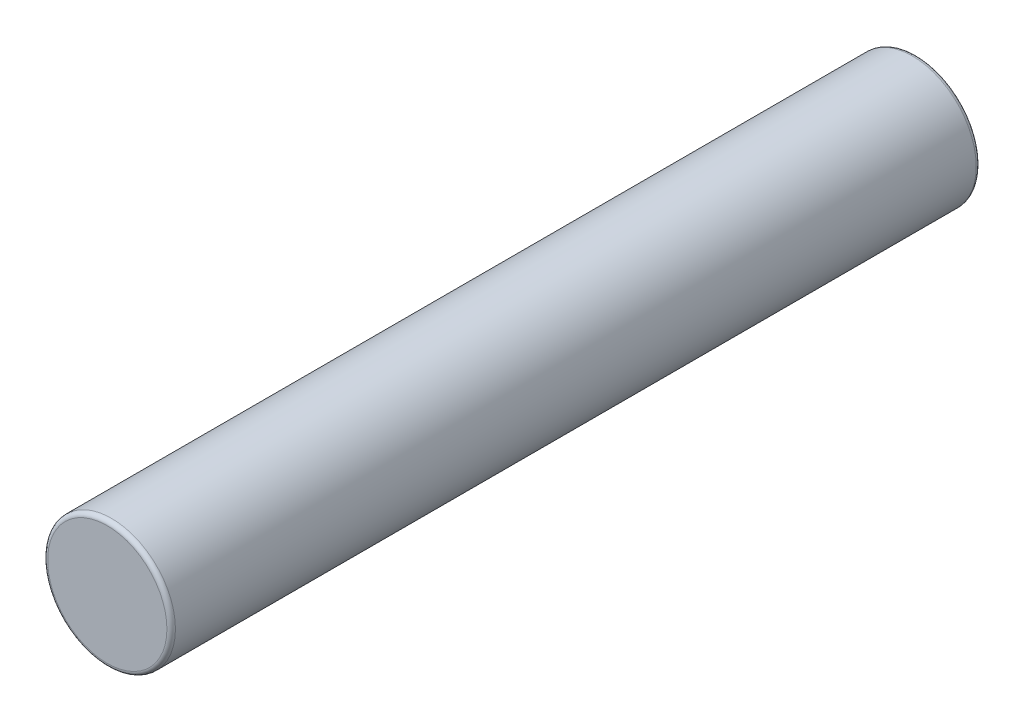
from build123d import *

# Parameters (mm, degrees)
CROQUIS1_R                   = 0.75
SALIENTE_EXTRUIR1_DEPTH      = 4.75
SALIENTE_EXTRUIR1_DEPTH_BACK = 4.75
REDONDEO1_R                  = 0.05


with BuildPart() as part:
    # Croquis1 → Saliente-Extruir1 (new body, two sides)
    with BuildSketch(Plane.XY) as saliente_extruir1_sk:
        Circle(CROQUIS1_R)
    extrude(amount=SALIENTE_EXTRUIR1_DEPTH)
    extrude(saliente_extruir1_sk.sketch, amount=-SALIENTE_EXTRUIR1_DEPTH_BACK)

    # Redondeo1
    redondeo1_edges = [part.edges().sort_by_distance(p)[0] for p in [
        (-0.75, 0, -4.75),
        (-0.75, 0, 4.75),
    ]]
    fillet(redondeo1_edges, radius=REDONDEO1_R)


solid = part.part
